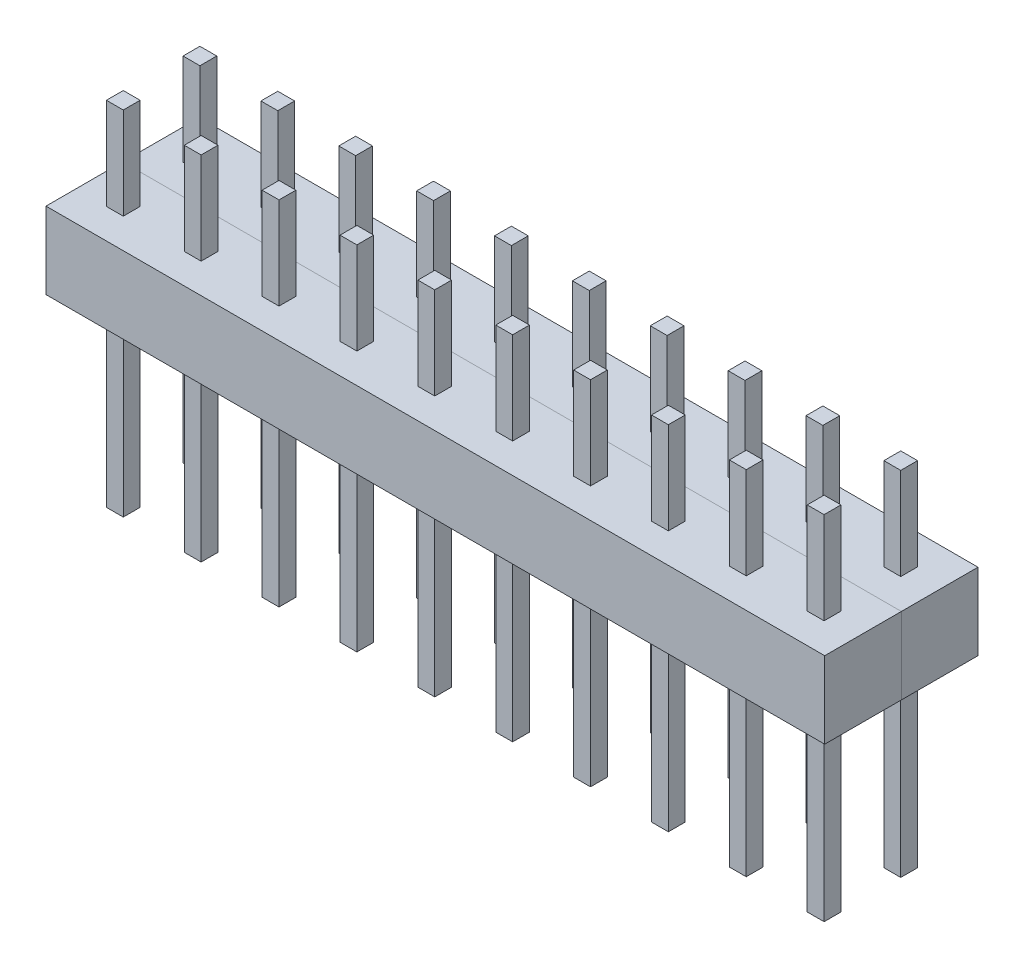
from build123d import *

# Parameters (mm, degrees)
SKETCH1_W              = 25.4
SKETCH1_H              = 2.5
BOSS_EXTRUDE1_DEPTH    = 1.25
SKETCH2_W              = 0.55
SKETCH2_H              = 0.55
BOSS_EXTRUDE2_DEPTH    = 6
BOSS_EXTRUDE2_2_DEPTH  = 6
BOSS_EXTRUDE2_3_DEPTH  = 6
BOSS_EXTRUDE2_4_DEPTH  = 6
BOSS_EXTRUDE2_5_DEPTH  = 6
BOSS_EXTRUDE2_6_DEPTH  = 6
BOSS_EXTRUDE2_7_DEPTH  = 6
BOSS_EXTRUDE2_8_DEPTH  = 6
BOSS_EXTRUDE2_9_DEPTH  = 6
BOSS_EXTRUDE2_10_DEPTH = 6
SKETCH2_2_W            = 0.55
SKETCH2_2_H            = 0.55
BOSS_EXTRUDE3_DEPTH    = 5.5
BOSS_EXTRUDE3_2_DEPTH  = 5.5
BOSS_EXTRUDE3_3_DEPTH  = 5.5
BOSS_EXTRUDE3_4_DEPTH  = 5.5
BOSS_EXTRUDE3_5_DEPTH  = 5.5
BOSS_EXTRUDE3_6_DEPTH  = 5.5
BOSS_EXTRUDE3_7_DEPTH  = 5.5
BOSS_EXTRUDE3_8_DEPTH  = 5.5
BOSS_EXTRUDE3_9_DEPTH  = 5.5
BOSS_EXTRUDE3_10_DEPTH = 5.5


with BuildPart() as part:
    # Sketch1 → Boss-Extrude1 (new, symmetric)
    with BuildSketch(Plane.XY):
        with Locations((12.7, 1.25)):
            Rectangle(SKETCH1_W, SKETCH1_H)
    extrude(amount=BOSS_EXTRUDE1_DEPTH, both=True)


with BuildPart() as body_2:
    # Sketch2 → Boss-Extrude2 (new body)
    with BuildSketch(Plane.XZ):
        with Locations((3.81, 0)):
            Rectangle(SKETCH2_W, SKETCH2_H)
    extrude(amount=BOSS_EXTRUDE2_DEPTH)


with BuildPart() as body_3:
    # Sketch2 → Boss-Extrude2 2 (new body)
    with BuildSketch(Plane.XZ):
        with Locations((1.27, 0)):
            Rectangle(SKETCH2_W, SKETCH2_H)
    extrude(amount=BOSS_EXTRUDE2_2_DEPTH)


with BuildPart() as body_4:
    # Sketch2 → Boss-Extrude2 3 (new body)
    with BuildSketch(Plane.XZ):
        with Locations((6.35, 0)):
            Rectangle(SKETCH2_W, SKETCH2_H)
    extrude(amount=BOSS_EXTRUDE2_3_DEPTH)


with BuildPart() as body_5:
    # Sketch2 → Boss-Extrude2 4 (new body)
    with BuildSketch(Plane.XZ):
        with Locations((8.89, 0)):
            Rectangle(SKETCH2_W, SKETCH2_H)
    extrude(amount=BOSS_EXTRUDE2_4_DEPTH)


with BuildPart() as body_6:
    # Sketch2 → Boss-Extrude2 5 (new body)
    with BuildSketch(Plane.XZ):
        with Locations((11.43, 0)):
            Rectangle(SKETCH2_W, SKETCH2_H)
    extrude(amount=BOSS_EXTRUDE2_5_DEPTH)


with BuildPart() as body_7:
    # Sketch2 → Boss-Extrude2 6 (new body)
    with BuildSketch(Plane.XZ):
        with Locations((13.97, 0)):
            Rectangle(SKETCH2_W, SKETCH2_H)
    extrude(amount=BOSS_EXTRUDE2_6_DEPTH)


with BuildPart() as body_8:
    # Sketch2 → Boss-Extrude2 7 (new body)
    with BuildSketch(Plane.XZ):
        with Locations((16.51, 0)):
            Rectangle(SKETCH2_W, SKETCH2_H)
    extrude(amount=BOSS_EXTRUDE2_7_DEPTH)


with BuildPart() as body_9:
    # Sketch2 → Boss-Extrude2 8 (new body)
    with BuildSketch(Plane.XZ):
        with Locations((19.05, 0)):
            Rectangle(SKETCH2_W, SKETCH2_H)
    extrude(amount=BOSS_EXTRUDE2_8_DEPTH)


with BuildPart() as body_10:
    # Sketch2 → Boss-Extrude2 9 (new body)
    with BuildSketch(Plane.XZ):
        with Locations((21.59, 0)):
            Rectangle(SKETCH2_W, SKETCH2_H)
    extrude(amount=BOSS_EXTRUDE2_9_DEPTH)


with BuildPart() as body_11:
    # Sketch2 → Boss-Extrude2 10 (new body)
    with BuildSketch(Plane.XZ):
        with Locations((24.13, 0)):
            Rectangle(SKETCH2_W, SKETCH2_H)
    extrude(amount=BOSS_EXTRUDE2_10_DEPTH)


with BuildPart() as body_12:
    # Sketch2_2 → Boss-Extrude3 (new body)
    with BuildSketch(Plane.XZ):
        with Locations((3.81, 0)):
            Rectangle(SKETCH2_2_W, SKETCH2_2_H)
    extrude(amount=-BOSS_EXTRUDE3_DEPTH)


with BuildPart() as body_13:
    # Sketch2_2 → Boss-Extrude3 2 (new body)
    with BuildSketch(Plane.XZ):
        with Locations((1.27, 0)):
            Rectangle(SKETCH2_2_W, SKETCH2_2_H)
    extrude(amount=-BOSS_EXTRUDE3_2_DEPTH)


with BuildPart() as body_14:
    # Sketch2_2 → Boss-Extrude3 3 (new body)
    with BuildSketch(Plane.XZ):
        with Locations((6.35, 0)):
            Rectangle(SKETCH2_2_W, SKETCH2_2_H)
    extrude(amount=-BOSS_EXTRUDE3_3_DEPTH)


with BuildPart() as body_15:
    # Sketch2_2 → Boss-Extrude3 4 (new body)
    with BuildSketch(Plane.XZ):
        with Locations((8.89, 0)):
            Rectangle(SKETCH2_2_W, SKETCH2_2_H)
    extrude(amount=-BOSS_EXTRUDE3_4_DEPTH)


with BuildPart() as body_16:
    # Sketch2_2 → Boss-Extrude3 5 (new body)
    with BuildSketch(Plane.XZ):
        with Locations((11.43, 0)):
            Rectangle(SKETCH2_2_W, SKETCH2_2_H)
    extrude(amount=-BOSS_EXTRUDE3_5_DEPTH)


with BuildPart() as body_17:
    # Sketch2_2 → Boss-Extrude3 6 (new body)
    with BuildSketch(Plane.XZ):
        with Locations((13.97, 0)):
            Rectangle(SKETCH2_2_W, SKETCH2_2_H)
    extrude(amount=-BOSS_EXTRUDE3_6_DEPTH)


with BuildPart() as body_18:
    # Sketch2_2 → Boss-Extrude3 7 (new body)
    with BuildSketch(Plane.XZ):
        with Locations((16.51, 0)):
            Rectangle(SKETCH2_2_W, SKETCH2_2_H)
    extrude(amount=-BOSS_EXTRUDE3_7_DEPTH)


with BuildPart() as body_19:
    # Sketch2_2 → Boss-Extrude3 8 (new body)
    with BuildSketch(Plane.XZ):
        with Locations((19.05, 0)):
            Rectangle(SKETCH2_2_W, SKETCH2_2_H)
    extrude(amount=-BOSS_EXTRUDE3_8_DEPTH)


with BuildPart() as body_20:
    # Sketch2_2 → Boss-Extrude3 9 (new body)
    with BuildSketch(Plane.XZ):
        with Locations((21.59, 0)):
            Rectangle(SKETCH2_2_W, SKETCH2_2_H)
    extrude(amount=-BOSS_EXTRUDE3_9_DEPTH)


with BuildPart() as body_21:
    # Sketch2_2 → Boss-Extrude3 10 (new body)
    with BuildSketch(Plane.XZ):
        with Locations((24.13, 0)):
            Rectangle(SKETCH2_2_W, SKETCH2_2_H)
    extrude(amount=-BOSS_EXTRUDE3_10_DEPTH)


with BuildPart() as body_22:
    # Mirror1: mirrored copy
    add(part.part.mirror(Plane(origin=(0, 0, 1.25), x_dir=(1, 0, 0), z_dir=(0, 0, -1))))


with BuildPart() as body_23:
    # Mirror1 2: mirrored copy
    add(body_13.part.mirror(Plane(origin=(0, 0, 1.25), x_dir=(1, 0, 0), z_dir=(0, 0, -1))))


with BuildPart() as body_24:
    # Mirror1 3: mirrored copy
    add(body_12.part.mirror(Plane(origin=(0, 0, 1.25), x_dir=(1, 0, 0), z_dir=(0, 0, -1))))


with BuildPart() as body_25:
    # Mirror1 4: mirrored copy
    add(body_14.part.mirror(Plane(origin=(0, 0, 1.25), x_dir=(1, 0, 0), z_dir=(0, 0, -1))))


with BuildPart() as body_26:
    # Mirror1 5: mirrored copy
    add(body_15.part.mirror(Plane(origin=(0, 0, 1.25), x_dir=(1, 0, 0), z_dir=(0, 0, -1))))


with BuildPart() as body_27:
    # Mirror1 6: mirrored copy
    add(body_16.part.mirror(Plane(origin=(0, 0, 1.25), x_dir=(1, 0, 0), z_dir=(0, 0, -1))))


with BuildPart() as body_28:
    # Mirror1 7: mirrored copy
    add(body_17.part.mirror(Plane(origin=(0, 0, 1.25), x_dir=(1, 0, 0), z_dir=(0, 0, -1))))


with BuildPart() as body_29:
    # Mirror1 8: mirrored copy
    add(body_18.part.mirror(Plane(origin=(0, 0, 1.25), x_dir=(1, 0, 0), z_dir=(0, 0, -1))))


with BuildPart() as body_30:
    # Mirror1 9: mirrored copy
    add(body_19.part.mirror(Plane(origin=(0, 0, 1.25), x_dir=(1, 0, 0), z_dir=(0, 0, -1))))


with BuildPart() as body_31:
    # Mirror1 10: mirrored copy
    add(body_20.part.mirror(Plane(origin=(0, 0, 1.25), x_dir=(1, 0, 0), z_dir=(0, 0, -1))))


with BuildPart() as body_32:
    # Mirror1 11: mirrored copy
    add(body_21.part.mirror(Plane(origin=(0, 0, 1.25), x_dir=(1, 0, 0), z_dir=(0, 0, -1))))


with BuildPart() as body_33:
    # Mirror1 12: mirrored copy
    add(body_11.part.mirror(Plane(origin=(0, 0, 1.25), x_dir=(1, 0, 0), z_dir=(0, 0, -1))))


with BuildPart() as body_34:
    # Mirror1 13: mirrored copy
    add(body_10.part.mirror(Plane(origin=(0, 0, 1.25), x_dir=(1, 0, 0), z_dir=(0, 0, -1))))


with BuildPart() as body_35:
    # Mirror1 14: mirrored copy
    add(body_9.part.mirror(Plane(origin=(0, 0, 1.25), x_dir=(1, 0, 0), z_dir=(0, 0, -1))))


with BuildPart() as body_36:
    # Mirror1 15: mirrored copy
    add(body_8.part.mirror(Plane(origin=(0, 0, 1.25), x_dir=(1, 0, 0), z_dir=(0, 0, -1))))


with BuildPart() as body_37:
    # Mirror1 16: mirrored copy
    add(body_7.part.mirror(Plane(origin=(0, 0, 1.25), x_dir=(1, 0, 0), z_dir=(0, 0, -1))))


with BuildPart() as body_38:
    # Mirror1 17: mirrored copy
    add(body_6.part.mirror(Plane(origin=(0, 0, 1.25), x_dir=(1, 0, 0), z_dir=(0, 0, -1))))


with BuildPart() as body_39:
    # Mirror1 18: mirrored copy
    add(body_5.part.mirror(Plane(origin=(0, 0, 1.25), x_dir=(1, 0, 0), z_dir=(0, 0, -1))))


with BuildPart() as body_40:
    # Mirror1 19: mirrored copy
    add(body_4.part.mirror(Plane(origin=(0, 0, 1.25), x_dir=(1, 0, 0), z_dir=(0, 0, -1))))


with BuildPart() as body_41:
    # Mirror1 20: mirrored copy
    add(body_2.part.mirror(Plane(origin=(0, 0, 1.25), x_dir=(1, 0, 0), z_dir=(0, 0, -1))))


with BuildPart() as body_42:
    # Mirror1 21: mirrored copy
    add(body_3.part.mirror(Plane(origin=(0, 0, 1.25), x_dir=(1, 0, 0), z_dir=(0, 0, -1))))


solid = Compound([part.part, body_2.part, body_3.part, body_4.part, body_5.part, body_6.part, body_7.part, body_8.part, body_9.part, body_10.part, body_11.part, body_12.part, body_13.part, body_14.part, body_15.part, body_16.part, body_17.part, body_18.part, body_19.part, body_20.part, body_21.part, body_22.part, body_23.part, body_24.part, body_25.part, body_26.part, body_27.part, body_28.part, body_29.part, body_30.part, body_31.part, body_32.part, body_33.part, body_34.part, body_35.part, body_36.part, body_37.part, body_38.part, body_39.part, body_40.part, body_41.part, body_42.part])
